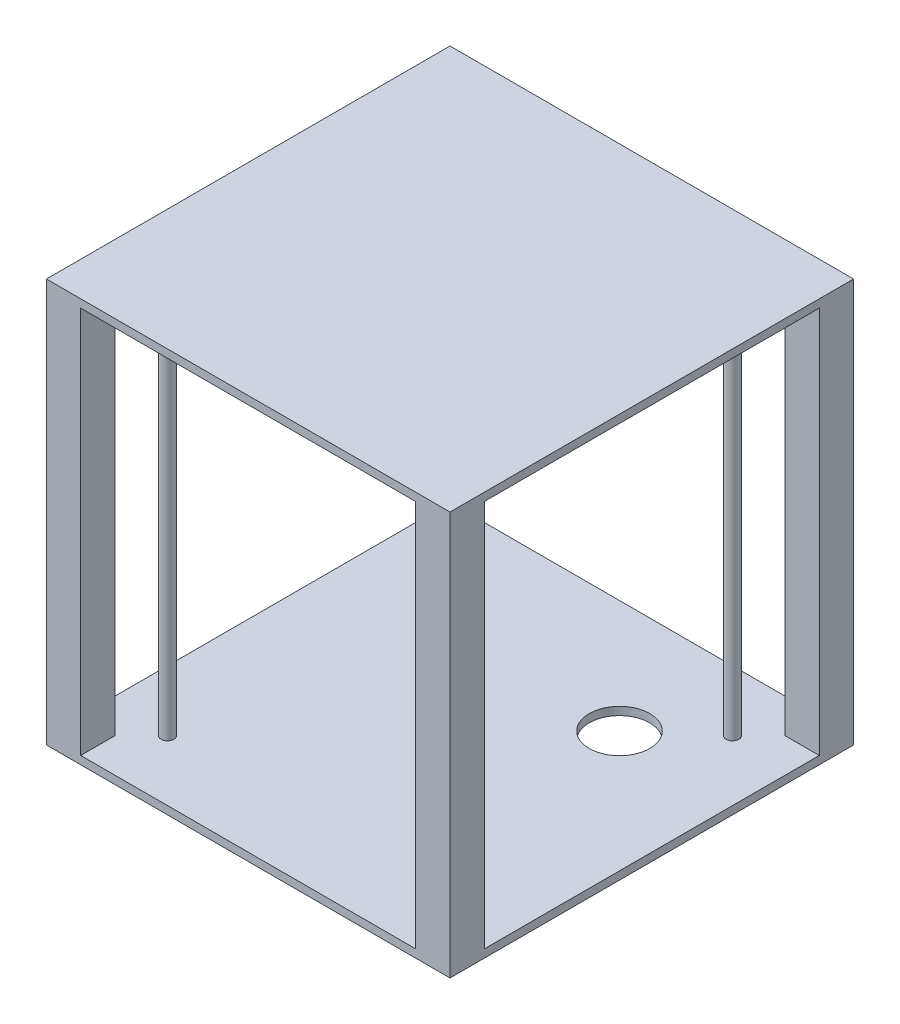
from build123d import *

# Parameters (mm, degrees)
SKETCH1_W            = 100
SKETCH1_H            = 100
BASE_DEPTH           = 2
SKETCH2_W            = 8.5
SKETCH2_H            = 8.5
BOSS_EXTRUDE2_DEPTH  = 96
LPATTERN1_COUNT      = 2
LPATTERN1_PITCH      = 91.5
LPATTERN1_COUNT_DIR2 = 2
LPATTERN1_PITCH_DIR2 = 91.5
LPATTERN2_COUNT      = 2
LPATTERN2_PITCH      = 98
SKETCH3_R            = 1.575
RODS_DEPTH           = 96
LPATTERN3_COUNT      = 2
LPATTERN3_PITCH      = 70
LPATTERN3_COUNT_DIR2 = 2
LPATTERN3_PITCH_DIR2 = 70
SKETCH5_R            = 7.5
CUT_EXTRUDE1_DEPTH   = 10


with BuildPart() as part:
    # Sketch1 → Base (new body)
    with BuildSketch(Plane(origin=(0, 0, 0), x_dir=(1, 0, 0), z_dir=(0, 1, 0))):
        with Locations((50, 50)):
            Rectangle(SKETCH1_W, SKETCH1_H)
    base = extrude(amount=BASE_DEPTH)

    # Sketch2 → Boss-Extrude2 (add)
    with BuildSketch(Plane(origin=(0, 2, 0), x_dir=(1, 0, 0), z_dir=(0, 1, 0))):
        with Locations((4.25, 4.25)):
            Rectangle(SKETCH2_W, SKETCH2_H)
    boss_extrude2 = extrude(amount=BOSS_EXTRUDE2_DEPTH)

    # LPattern1: Boss-Extrude2 2 × 2
    with Locations(*[(j * LPATTERN1_PITCH_DIR2, 0, -i * LPATTERN1_PITCH) for i in range(LPATTERN1_COUNT) for j in range(LPATTERN1_COUNT_DIR2) if (i, j) != (0, 0)]):
        add(boss_extrude2)

    # LPattern2: Base ×2
    with Locations(*[(0, i * LPATTERN2_PITCH, 0) for i in range(1, LPATTERN2_COUNT)]):
        add(base)

    # Sketch3 → Rods (add)
    with BuildSketch(Plane(origin=(0, 2, 0), x_dir=(1, 0, 0), z_dir=(0, 1, 0))):
        with Locations((15, 85)):
            Circle(SKETCH3_R)
    rods = extrude(amount=RODS_DEPTH)

    # LPattern3: Rods 2 × 2
    with Locations(*[(i * LPATTERN3_PITCH, 0, j * LPATTERN3_PITCH_DIR2) for i in range(LPATTERN3_COUNT) for j in range(LPATTERN3_COUNT_DIR2) if (i, j) != (0, 0)]):
        add(rods)

    # Sketch5 → Cut-Extrude1 (cut)
    with BuildSketch(Plane(origin=(0, 2, 0), x_dir=(1, 0, 0), z_dir=(0, 1, 0))):
        with Locations((70, 72)):
            Circle(SKETCH5_R)
    extrude(amount=-CUT_EXTRUDE1_DEPTH, mode=Mode.SUBTRACT)


solid = part.part
